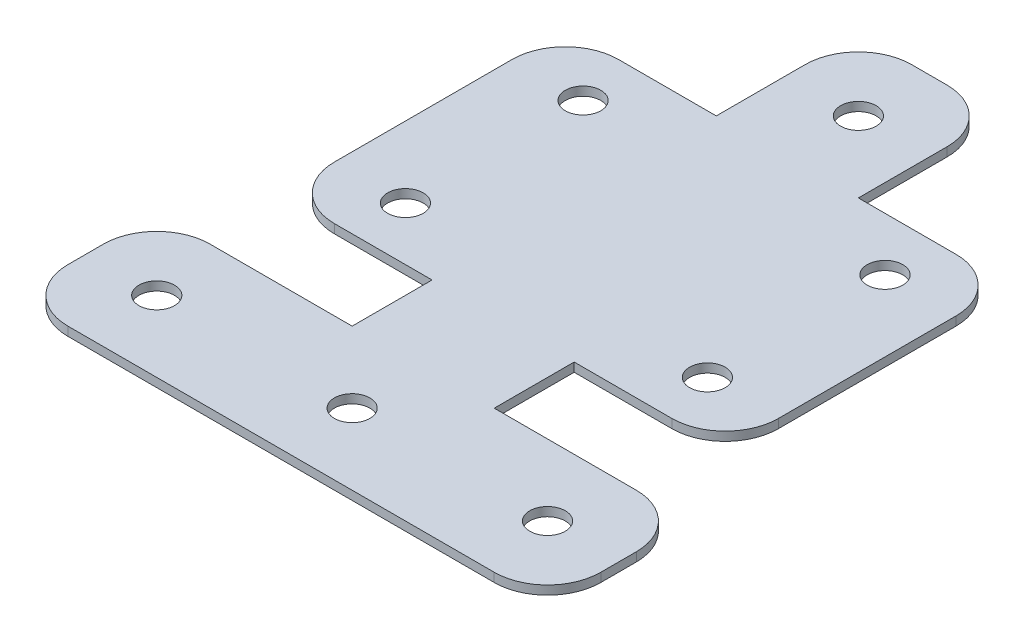
from build123d import *

# Parameters (mm, degrees)
SKETCH1_R           = 3.175
BOSS_EXTRUDE1_DEPTH = 1.5875
FILLET1_R           = 9.525


with BuildPart() as part:
    # Sketch1 → Boss-Extrude1 (new body)
    with BuildSketch(Plane(origin=(0, 0, 0), x_dir=(1, 0, 0), z_dir=(0, 1, 0))):
        Polygon((12.7, 12.7), (14.2875, 12.7), (20.6375, 12.7), (22.225, 12.7), (47.625, 12.7), (47.625, -12.7), (22.225, -12.7), (12.7, -12.7), (-12.7, -12.7), (-22.225, -12.7), (-47.625, -12.7), (-47.625, 12.7), (-22.225, 12.7), (-12.7, 12.7), (-12.7, 25.4), (-12.7, 26.9875), (-14.2875, 26.9875), (-39.6875, 26.9875), (-39.6875, 77.7875), (-14.2875, 77.7875), (-12.7, 77.7875), (-12.7, 103.1875), (12.7, 103.1875), (12.7, 77.7875), (14.2875, 77.7875), (39.6875, 77.7875), (39.6875, 26.9875), (14.2875, 26.9875), (12.7, 26.9875), (12.7, 25.4), align=None)
        with Locations((26.9875, 36.5125)):
            Circle(SKETCH1_R, mode=Mode.SUBTRACT)
        with Locations((26.9875, 68.2625)):
            Circle(SKETCH1_R, mode=Mode.SUBTRACT)
        with Locations((0, 90.4875)):
            Circle(SKETCH1_R, mode=Mode.SUBTRACT)
        with Locations((34.925, 0)):
            Circle(SKETCH1_R, mode=Mode.SUBTRACT)
        Circle(SKETCH1_R, mode=Mode.SUBTRACT)
        with Locations((-34.925, 0)):
            Circle(SKETCH1_R, mode=Mode.SUBTRACT)
        with Locations((-26.9875, 68.2625)):
            Circle(SKETCH1_R, mode=Mode.SUBTRACT)
        with Locations((-26.9875, 36.5125)):
            Circle(SKETCH1_R, mode=Mode.SUBTRACT)
    extrude(amount=BOSS_EXTRUDE1_DEPTH)

    # Fillet1
    fillet1_edges = [part.edges().sort_by_distance(p)[0] for p in [
        (47.625, 0.79375, -12.7),
        (47.625, 0.79375, 12.7),
        (-47.625, 0.79375, 12.7),
        (-47.625, 0.79375, -12.7),
        (-39.6875, 0.79375, -26.9875),
        (-39.6875, 0.79375, -77.7875),
        (-12.7, 0.79375, -103.1875),
        (12.7, 0.79375, -103.1875),
        (39.6875, 0.79375, -77.7875),
        (39.6875, 0.79375, -26.9875),
    ]]
    fillet(fillet1_edges, radius=FILLET1_R)


solid = part.part
